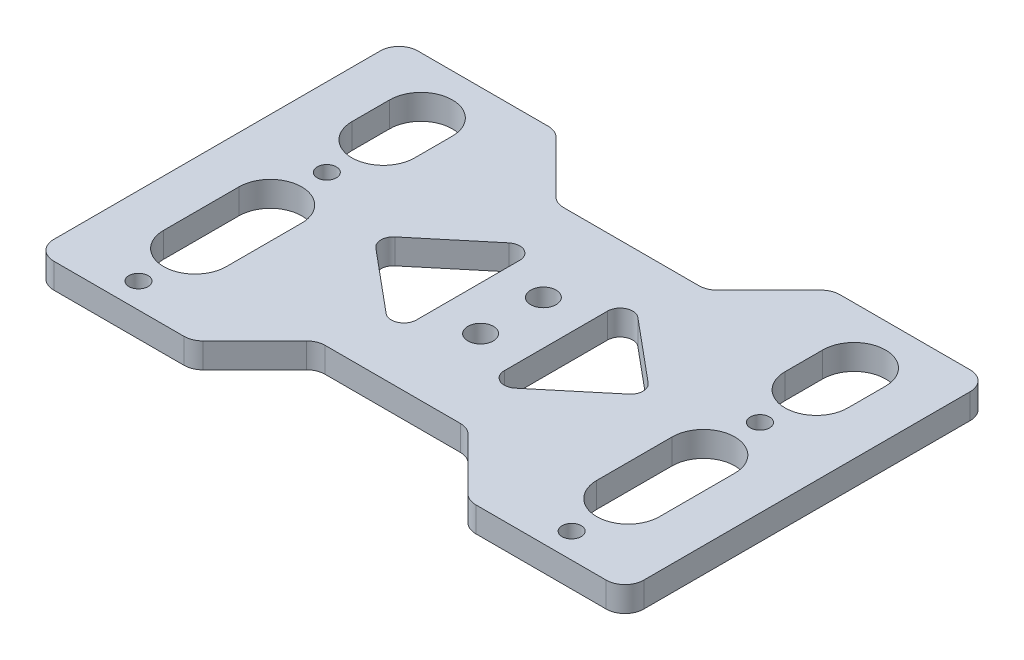
from build123d import *

# Parameters (mm, degrees)
SKETCH_1_W          = 94
SKETCH_1_H          = 58
EXTRUDE_1_DEPTH     = 4
FILLET_1_R          = 3
SKETCH_2_R          = 1.525
CUT_EXTRUDE_1_DEPTH = 10
CUT_EXTRUDE_2_DEPTH = 10
SKETCH_4_R          = 2.025
CUT_EXTRUDE_3_DEPTH = 10
CUT_EXTRUDE_4_DEPTH = 10
FILLET_2_R          = 2
FILLET_3_R          = 3


with BuildPart() as part:
    # 草图1 → 凸台-拉伸1 (new body)
    with BuildSketch(Plane(origin=(0, 0, 0), x_dir=(1, 0, 0), z_dir=(0, 1, 0))):
        Rectangle(SKETCH_1_W, SKETCH_1_H)
    extrude(amount=EXTRUDE_1_DEPTH)

    # 圆角1
    fillet_1_edges = [part.edges().sort_by_distance(p)[0] for p in [
        (47, 2, 29),
        (-47, 2, 29),
        (-47, 2, -29),
        (47, 2, -29),
    ]]
    fillet(fillet_1_edges, radius=FILLET_1_R)

    # 草图2 → 切除-拉伸1 (cut)
    with BuildSketch(Plane(origin=(0, 4, 0), x_dir=(1, 0, 0), z_dir=(0, 1, 0))):
        with Locations((-34.500000003, 5)):
            Circle(SKETCH_2_R)
        with Locations((-34.500000003, -25)):
            Circle(SKETCH_2_R)
        with BuildLine():
            Line((-39.500000003, 14), (-39.500000003, 20))
            ThreePointArc((-39.500000003, 20), (-34.500000003, 25), (-29.500000003, 20))
            Line((-29.500000003, 20), (-29.500000003, 14))
            ThreePointArc((-29.500000003, 14), (-34.500000003, 9), (-39.500000003, 14))
        make_face()
        with BuildLine():
            Line((-39.500000003, -16), (-39.500000003, -4))
            ThreePointArc((-39.500000003, -4), (-34.500000003, 1), (-29.500000003, -4))
            Line((-29.500000003, -4), (-29.500000003, -16))
            ThreePointArc((-29.500000003, -16), (-34.500000003, -21), (-39.500000003, -16))
        make_face()
    cut_extrude_1 = extrude(amount=-CUT_EXTRUDE_1_DEPTH, mode=Mode.SUBTRACT)

    # 镜向1: 切除-拉伸1 across plane
    add(cut_extrude_1.mirror(Plane(origin=(0, 0, 0), x_dir=(0, 0, 1), z_dir=(1, 0, 0))), mode=Mode.SUBTRACT)

    # 草图3 → 切除-拉伸2 (cut)
    with BuildSketch(Plane.XZ):
        Polygon((-22, 29), (-12, 19), (12, 19), (22, 29), align=None)
    cut_extrude_2 = extrude(amount=-CUT_EXTRUDE_2_DEPTH, mode=Mode.SUBTRACT)

    # 镜向2: 切除-拉伸2 across plane
    add(cut_extrude_2.mirror(Plane.XY), mode=Mode.SUBTRACT)

    # 草图4 → 切除-拉伸3 (cut)
    with BuildSketch(Plane.XZ):
        with Locations((0, 5)):
            Circle(SKETCH_4_R)
        with Locations((0, -5)):
            Circle(SKETCH_4_R)
    extrude(amount=-CUT_EXTRUDE_3_DEPTH, mode=Mode.SUBTRACT)

    # 草图5 → 切除-拉伸4 (cut)
    with BuildSketch(Plane.XZ):
        Polygon((-7, 12.5), (-7, -12.5), (-22, 0), align=None)
        Polygon((22, 0), (7, 12.5), (7, -12.5), align=None)
    extrude(amount=-CUT_EXTRUDE_4_DEPTH, mode=Mode.SUBTRACT)

    # 圆角2
    fillet_2_edges = [part.edges().sort_by_distance(p)[0] for p in [
        (-22, 2, 0),
        (-7, 2, 12.5),
        (-7, 2, -12.5),
        (22, 2, 0),
        (7, 2, -12.5),
        (7, 2, 12.5),
    ]]
    fillet(fillet_2_edges, radius=FILLET_2_R)

    # 圆角3
    fillet_3_edges = [part.edges().sort_by_distance(p)[0] for p in [
        (-22, 2, 29),
        (22, 2, 29),
        (12, 2, 19),
        (-12, 2, 19),
        (22, 2, -29),
        (-22, 2, -29),
        (-12, 2, -19),
        (12, 2, -19),
    ]]
    fillet(fillet_3_edges, radius=FILLET_3_R)


solid = part.part
